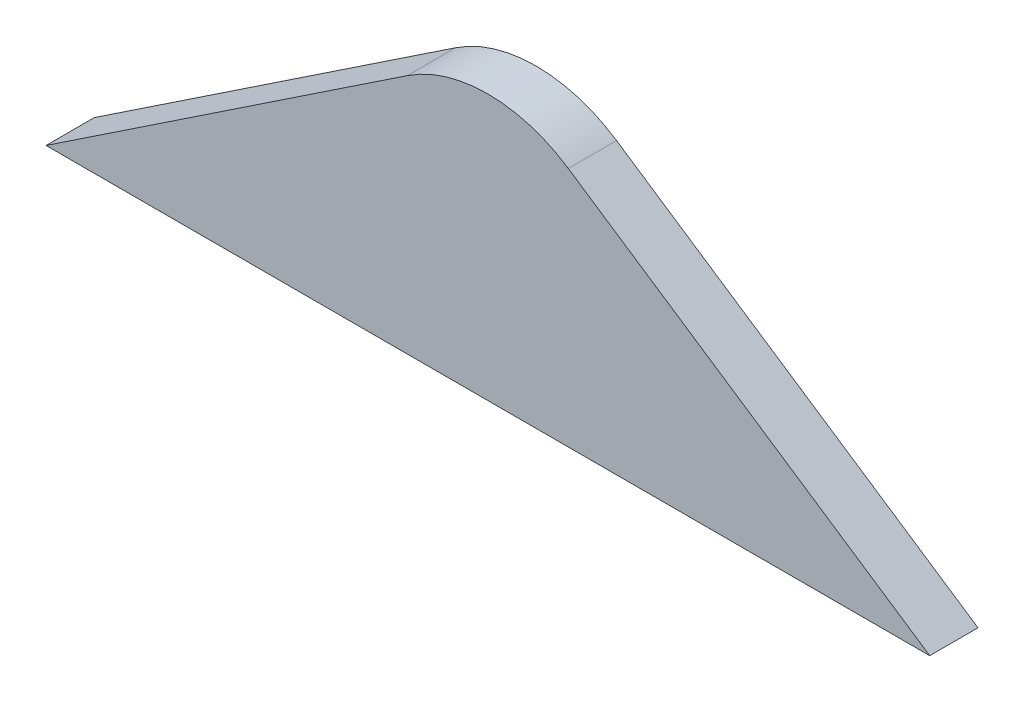
from build123d import *

# Parameters (mm, degrees)
DODANIE_WYCI_GNI_CIE1_DEPTH = 10


with BuildPart() as part:
    # Szkic1 → Dodanie-wyciągnięcie1 (new body)
    with BuildSketch(Plane.XY):
        with BuildLine():
            Line((0, 0), (183, 0))
            Line((183, 0), (108.15381541, 49.952964399))
            ThreePointArc((108.15381541, 49.952964399), (91.5, 55), (74.84618459, 49.952964399))
            Line((74.84618459, 49.952964399), (0, 0))
        make_face()
    extrude(amount=DODANIE_WYCI_GNI_CIE1_DEPTH)


solid = part.part
